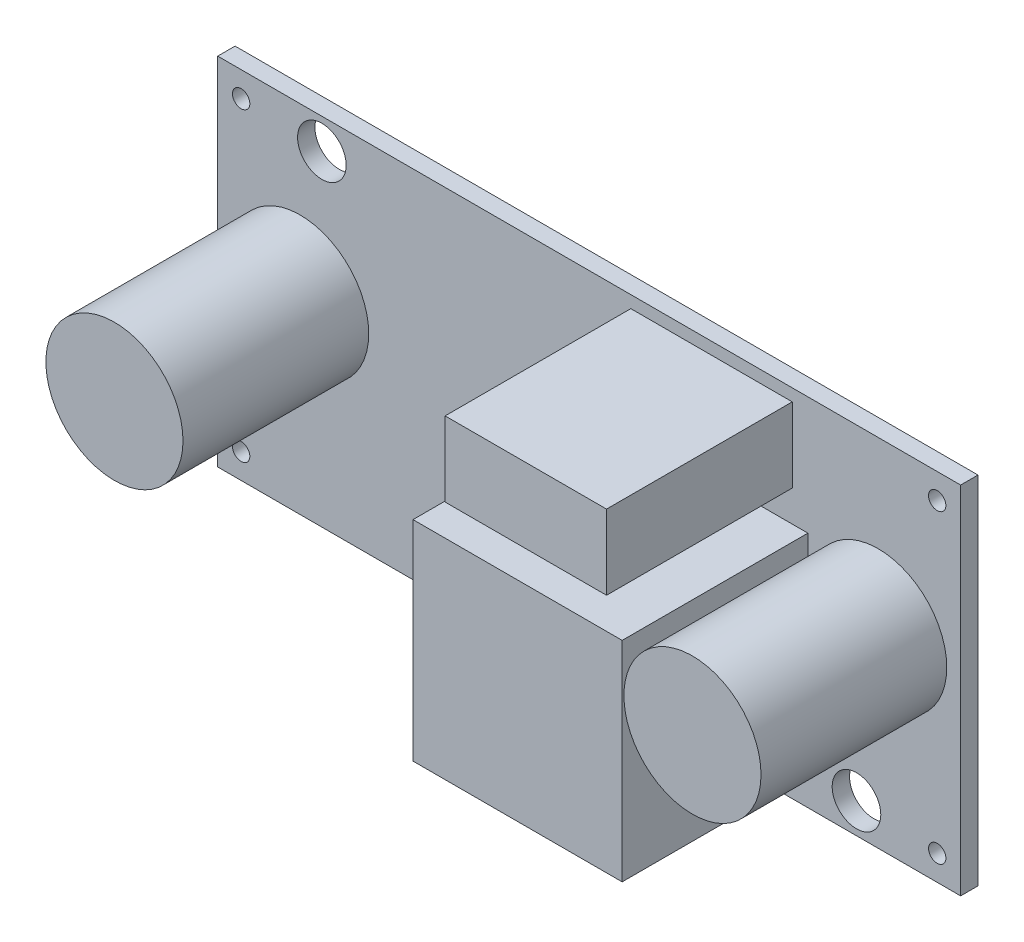
from build123d import *

# Parameters (mm, degrees)
SKETCH1_W           = 42.8
SKETCH1_H           = 20.5
SKETCH1_R           = 1.4
BOSS_EXTRUDE1_DEPTH = 1
SKETCH3_R           = 3.95
SKETCH3_W           = 9.3
SKETCH3_H           = 4.3
SKETCH3_W_2         = 12.05
SKETCH3_H_2         = 12.05
BOSS_EXTRUDE2_DEPTH = 10.7
SKETCH4_R           = 0.5
CUT_EXTRUDE1_DEPTH  = 2


with BuildPart() as part:
    # Sketch1 → Boss-Extrude1 (new body)
    with BuildSketch(Plane.XY):
        Rectangle(SKETCH1_W, SKETCH1_H)
        with Locations((15.4, -8.5)):
            Circle(SKETCH1_R, mode=Mode.SUBTRACT)
        with Locations((-15.4, 8.5)):
            Circle(SKETCH1_R, mode=Mode.SUBTRACT)
    extrude(amount=BOSS_EXTRUDE1_DEPTH)

    # Sketch3 → Boss-Extrude2 (add)
    with BuildSketch(Plane.XY.offset(1)):
        with Locations((16.65, 0.75)):
            Circle(SKETCH3_R)
        with Locations((-16.65, 0.75)):
            Circle(SKETCH3_R)
        with Locations((7.05, 7.4)):
            Rectangle(SKETCH3_W, SKETCH3_H)
        with Locations((6.575, -2.575)):
            Rectangle(SKETCH3_W_2, SKETCH3_H_2)
    extrude(amount=BOSS_EXTRUDE2_DEPTH)

    # Sketch4 → Cut-Extrude1 (cut, through all)
    with BuildSketch(Plane.XY.offset(1)):
        with Locations((-20.05, 8.8)):
            Circle(SKETCH4_R)
        with Locations((-20.05, -8.8)):
            Circle(SKETCH4_R)
        with Locations((20.05, -8.8)):
            Circle(SKETCH4_R)
        with Locations((20.05, 8.8)):
            Circle(SKETCH4_R)
    extrude(amount=-CUT_EXTRUDE1_DEPTH, mode=Mode.SUBTRACT)


solid = part.part
